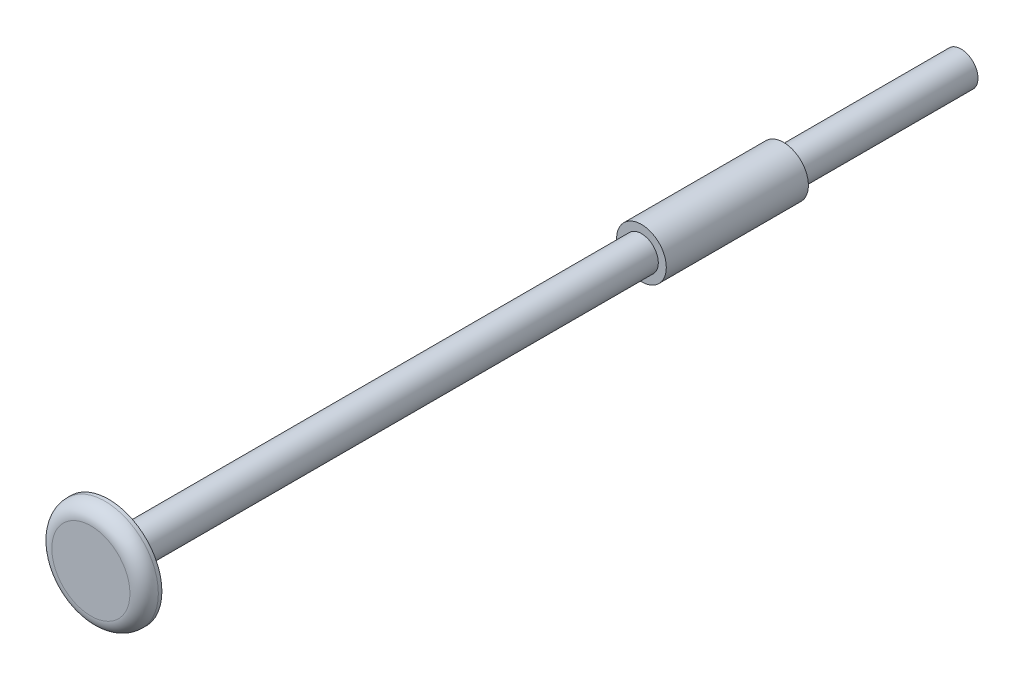
from build123d import *

# Parameters (mm, degrees)
SKETCH1_R           = 7.5
BOSS_EXTRUDE1_DEPTH = 2.5
SKETCH1_3_R         = 2.375
BOSS_EXTRUDE2_DEPTH = 120
BOSS_EXTRUDE3_START = -75
SKETCH1_4_R         = 3.5
SKETCH1_4_R_2       = 2.375
BOSS_EXTRUDE3_DEPTH = 20
FILLET1_R           = 2


with BuildPart() as part:
    # Sketch1 → Boss-Extrude1 (new body)
    with BuildSketch(Plane.XY):
        Circle(SKETCH1_R)
    extrude(amount=BOSS_EXTRUDE1_DEPTH)

    # Sketch1_3 → Boss-Extrude2 (add)
    with BuildSketch(Plane.XY):
        Circle(SKETCH1_3_R)
    extrude(amount=-BOSS_EXTRUDE2_DEPTH)

    # Sketch1_4 → Boss-Extrude3 (add)
    with BuildSketch(Plane.XY.offset(BOSS_EXTRUDE3_START)):
        Circle(SKETCH1_4_R)
        Circle(SKETCH1_4_R_2, mode=Mode.SUBTRACT)
    extrude(amount=-BOSS_EXTRUDE3_DEPTH)

    # Fillet1
    fillet1_edges = [part.edges().sort_by_distance(p)[0] for p in [
        (-7.5, 0, 2.5),
    ]]
    fillet(fillet1_edges, radius=FILLET1_R)


solid = part.part
